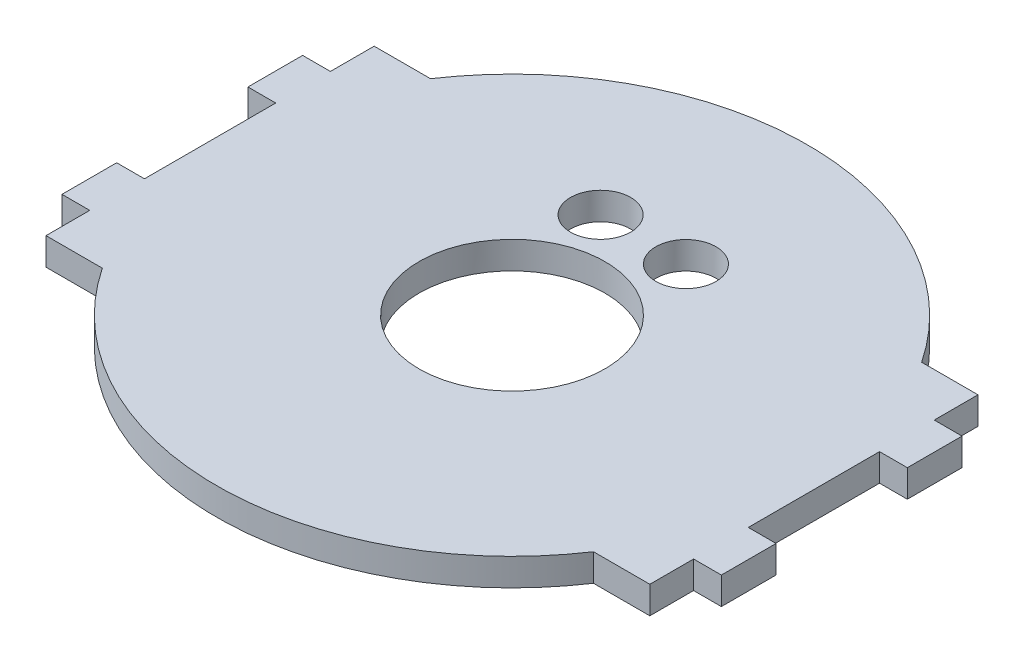
from build123d import *

# Parameters (mm, degrees)
SKETCH1_W                  = 70.104
SKETCH1_H                  = 38.1
RECTANGULAR_BASE_DEPTH     = 3.175
SKETCH2_R                  = 34.29
CIRCULAR_BASE_ADD_ON_DEPTH = 3.175
SKETCH4_W                  = 3.2258
SKETCH4_H                  = 6.35
TAB_DEPTH                  = 3.175
SKETCH5_R                  = 10.795
CUT_EXTRUDE1_DEPTH         = 4.175
SKETCH6_R                  = 3.4925
CUT_FOR_SCREW_ACCESS_DEPTH = 4.175


with BuildPart() as part:
    # Sketch1 → rectangular base (new body)
    with BuildSketch(Plane(origin=(0, 0, 0), x_dir=(1, 0, 0), z_dir=(0, 1, 0))):
        Rectangle(SKETCH1_W, SKETCH1_H)
    extrude(amount=RECTANGULAR_BASE_DEPTH)

    # Sketch2 → circular base add on (add)
    with BuildSketch(Plane(origin=(0, 3.175, 0), x_dir=(1, 0, 0), z_dir=(0, 1, 0))):
        Circle(SKETCH2_R)
    extrude(amount=-CIRCULAR_BASE_ADD_ON_DEPTH)

    # Sketch4 → tab (add)
    with BuildSketch(Plane(origin=(0, 3.175, 0), x_dir=(1, 0, 0), z_dir=(0, 1, 0))):
        with Locations((-36.6649, 10.795)):
            Rectangle(SKETCH4_W, SKETCH4_H)
        with Locations((-36.6649, -10.795)):
            Rectangle(SKETCH4_W, SKETCH4_H)
    tab = extrude(amount=-TAB_DEPTH)

    # Mirror1: tab across plane
    add(tab.mirror(Plane(origin=(0, 0, 0), x_dir=(0, 0, 1), z_dir=(1, 0, 0))))

    # Sketch5 → Cut-Extrude1 (cut, through all)
    with BuildSketch(Plane(origin=(0, 3.175, 0), x_dir=(1, 0, 0), z_dir=(0, 1, 0))):
        Circle(SKETCH5_R)
    extrude(amount=-CUT_EXTRUDE1_DEPTH, mode=Mode.SUBTRACT)

    # Sketch6 → cut for screw access (cut, through all)
    with BuildSketch(Plane(origin=(0, 3.175, 0), x_dir=(1, 0, 0), z_dir=(0, 1, 0))):
        with Locations((4.955, 15.24)):
            Circle(SKETCH6_R)
        with Locations((-4.955, 15.24)):
            Circle(SKETCH6_R)
    extrude(amount=-CUT_FOR_SCREW_ACCESS_DEPTH, mode=Mode.SUBTRACT)


solid = part.part
